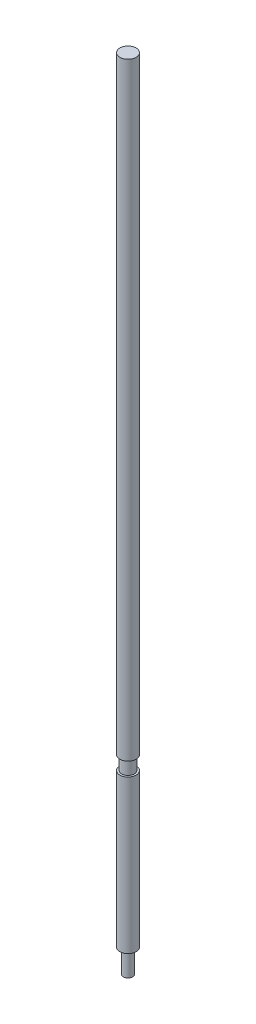
from build123d import *


with BuildPart() as part:
    # Croquis1 → Revolución1 (revolve)
    with BuildSketch(Plane.XY):
        Polygon((0, 290.401302326), (-4.14, 290.401302326), (-4.14, -19.598697674), (-3.185, -19.598697674), (-3.185, -26.598697674), (-4.14, -26.598697674), (-4.14, -104.598697674), (-2.385, -104.598697674), (-2.385, -116.598697674), (0, -116.598697674), align=None)
    revolve(axis=Axis((0, 19.92004864, 0), (0, -1, 0)))


solid = part.part
